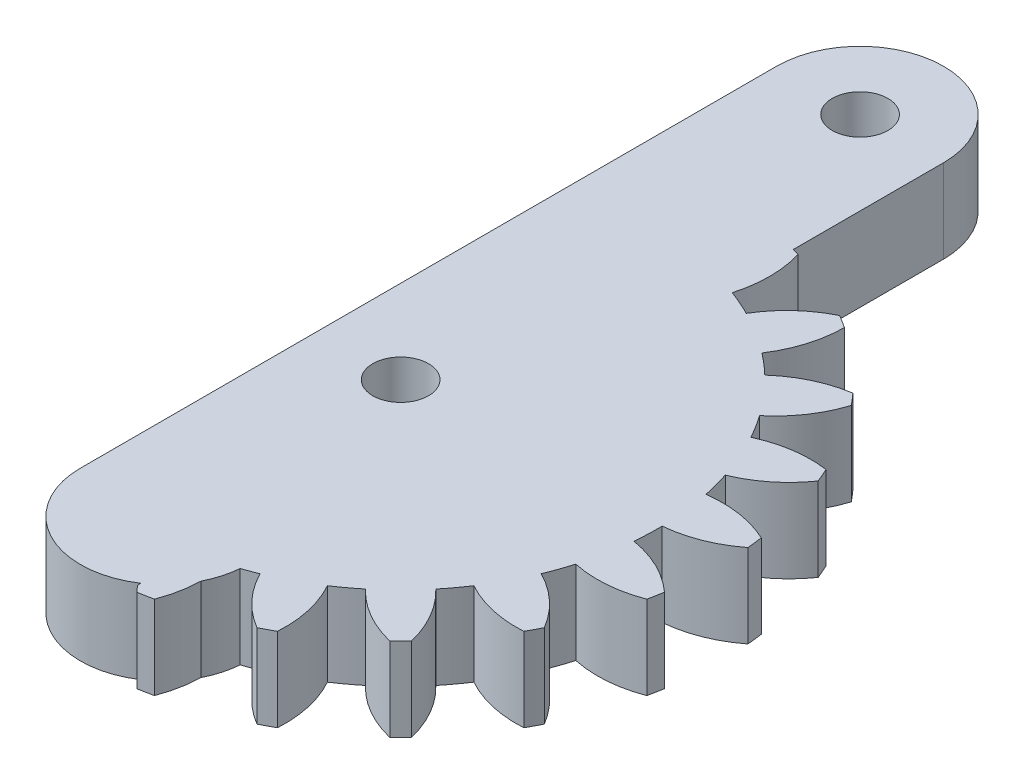
from build123d import *

# Parameters (mm, degrees)
BOSS_EXTRUDE1_DEPTH = 6
BOSS_EXTRUDE2_DEPTH = 6
SKETCH2_R           = 2
CUT_EXTRUDE1_DEPTH  = 7


with BuildPart() as part:
    # Sketch1 → Boss-Extrude1 (new body)
    with BuildSketch(Plane(origin=(0, 0, 0), x_dir=(1, 0, 0), z_dir=(0, 1, 0))):
        with BuildLine():
            Line((5.999994922, -17.000000726), (6.000000976, 32.999999274))
            ThreePointArc((6.000000976, 32.999999274), (3.1827e-05, 38.999972559), (-5.999944142, 33.000006094))
            Line((-5.999944142, 33.000006094), (-5.999994922, -16.999993906))
            ThreePointArc((-5.999994922, -16.999993906), (-3.41e-06, -22.999994922), (5.999994922, -17.000000726))
        make_face()
    extrude(amount=BOSS_EXTRUDE1_DEPTH)

    # Sketch4 → Boss-Extrude2 (add)
    with BuildSketch(Plane(origin=(0, 6, 0), x_dir=(1, 0, 0), z_dir=(0, 1, 0))):
        with BuildLine():
            Line((-2.743025532, 18.19970901), (3.351302477, -22.235567688))
            ThreePointArc((3.351302477, -22.235567688), (3.541272199, -22.468242769), (3.739439393, -22.693977021))
            ThreePointArc((3.739439393, -22.693977021), (4.275797924, -22.599060868), (4.809758376, -22.491470036))
            ThreePointArc((4.809758376, -22.491470036), (5.335701359, -20.15196829), (5.179210857, -17.759188492))
            ThreePointArc((5.179210857, -17.759188492), (6.10970176, -17.460943428), (7.023146788, -17.113982885))
            ThreePointArc((7.023146788, -17.113982885), (8.392641943, -19.082324182), (10.262473747, -20.583528186))
            ThreePointArc((10.262473747, -20.583528186), (10.747026347, -20.334734439), (11.225551479, -20.074535959))
            ThreePointArc((11.225551479, -20.074535959), (11.038548046, -17.683947297), (10.183725752, -15.443598376))
            ThreePointArc((10.183725752, -15.443598376), (10.984968279, -14.884336496), (11.755563092, -14.283547788))
            ThreePointArc((11.755563092, -14.283547788), (13.644394202, -15.760775419), (15.873642273, -16.644142542))
            ThreePointArc((15.873642273, -16.644142542), (16.263334316, -16.263577617), (16.643905071, -15.873891267))
            ThreePointArc((16.643905071, -15.873891267), (15.760571298, -13.644629981), (14.283371923, -11.755776772))
            ThreePointArc((14.283371923, -11.755776772), (14.884172159, -10.985190947), (15.443446026, -10.183956787))
            ThreePointArc((15.443446026, -10.183956787), (17.683782158, -11.038812596), (20.074368023, -11.225851792))
            ThreePointArc((20.074368023, -11.225851792), (20.334573661, -10.747330553), (20.583374658, -10.262781675))
            ThreePointArc((20.583374658, -10.262781675), (19.082198626, -8.392927413), (17.113877817, -7.023402811))
            ThreePointArc((17.113877817, -7.023402811), (17.460852025, -6.109962974), (17.759111009, -5.179476534))
            ThreePointArc((17.759111009, -5.179476534), (20.151888466, -5.336002831), (22.491398079, -4.810094847))
            ThreePointArc((22.491398079, -4.810094847), (22.5989969, -4.276136005), (22.693921077, -3.739778893))
            ThreePointArc((22.693921077, -3.739778893), (20.708288865, -2.395476413), (18.423740564, -1.66696869))
            ThreePointArc((18.423740564, -1.66696869), (18.486058563, -0.691837978), (18.496801044, 0.285222939))
            ThreePointArc((18.496801044, 0.285222939), (20.829411048, 0.840934203), (22.909968714, 2.033060135))
            ThreePointArc((22.909968714, 2.033060135), (22.855400089, 2.575011992), (22.788013017, 3.115519655))
            ThreePointArc((22.788013017, 3.115519655), (20.494356761, 3.814823179), (18.096573111, 3.837582915))
            ThreePointArc((18.096573111, 3.837582915), (17.868697673, 4.787759858), (17.590969135, 5.724579102))
            ThreePointArc((17.590969135, 5.724579102), (19.656149051, 6.943150542), (21.29288809, 8.695568802))
            ThreePointArc((21.29288809, 8.695568802), (21.081000682, 9.197358874), (20.857289998, 9.69399061))
            ThreePointArc((20.857289998, 9.69399061), (18.459411122, 9.686158991), (16.161445721, 9.001148437))
            ThreePointArc((16.161445721, 9.001148437), (15.66362458, 9.84194422), (15.122102421, 10.65528129))
            ThreePointArc((15.122102421, 10.65528129), (16.73635195, 12.428437486), (17.783840917, 14.58543802))
            ThreePointArc((17.783840917, 14.58543802), (17.433461851, 15.002480058), (17.073305232, 15.411107957))
            ThreePointArc((17.073305232, 15.411107957), (14.784265796, 14.696837069), (12.790302956, 13.36492242))
            ThreePointArc((12.790302956, 13.36492242), (12.066769703, 14.021628648), (11.309570545, 14.639214975))
            ThreePointArc((11.309570545, 14.639214975), (12.329456533, 16.809403218), (12.694621435, 19.179327064))
            ThreePointArc((12.694621435, 19.179327064), (12.23688343, 19.474565051), (11.77228237, 19.758880732))
            ThreePointArc((11.77228237, 19.758880732), (9.795473575, 18.401636677), (8.282685644, 16.541164395))
            ThreePointArc((8.282685644, 16.541164395), (7.397729384, 16.955429837), (6.492133694, 17.322390167))
            ThreePointArc((6.492133694, 17.322390167), (6.827034796, 19.696779708), (6.477429129, 22.069048731))
            ThreePointArc((6.477429129, 22.069048731), (5.953004215, 22.216249477), (5.425240559, 22.350990244))
            ThreePointArc((5.425240559, 22.350990244), (3.912805358, 20.430687649), (3.017264913, 18.156258137))
            ThreePointArc((3.017264913, 18.156258137), (0.138830127, 18.404736437), (-2.743025532, 18.19970901))
        make_face()
    extrude(amount=-BOSS_EXTRUDE2_DEPTH)

    # Sketch2 → Cut-Extrude1 (cut, through all)
    with BuildSketch(Plane(origin=(0, 6, 0), x_dir=(1, 0, 0), z_dir=(0, 1, 0))):
        Circle(SKETCH2_R)
        with Locations((0, 33)):
            Circle(SKETCH2_R)
    extrude(amount=-CUT_EXTRUDE1_DEPTH, mode=Mode.SUBTRACT)


solid = part.part
